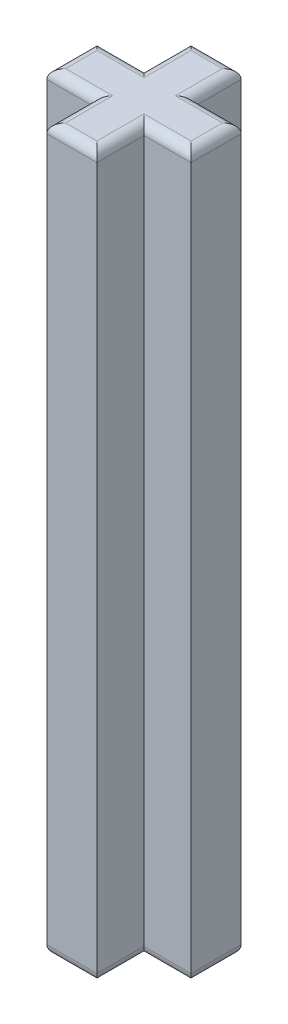
from build123d import *

# Parameters (mm, degrees)
BOSS_EXTRUDE1_DEPTH = 23
FILLET1_R           = 0.3


with BuildPart() as part:
    # Sketch1 → Boss-Extrude1 (new body)
    with BuildSketch(Plane(origin=(0, 0, 0), x_dir=(1, 0, 0), z_dir=(0, 1, 0))):
        Polygon((0.8, 0.8), (2.3, 0.8), (2.3, -0.8), (0.8, -0.8), (0.8, -2.3), (-0.8, -2.3), (-0.8, -0.8), (-2.3, -0.8), (-2.3, 0.8), (-0.8, 0.8), (-0.8, 2.3), (0.8, 2.3), align=None)
    extrude(amount=BOSS_EXTRUDE1_DEPTH)

    # Fillet1
    fillet1_edges = [part.edges().sort_by_distance(p)[0] for p in [
        (1.55, 0, 0.8),
        (0.8, 0, 1.55),
        (0.8, 23, -1.55),
        (0, 0, 2.3),
        (-0.8, 0, 1.55),
        (-1.55, 0, 0.8),
        (-2.3, 0, 0),
        (-1.55, 0, -0.8),
        (-0.8, 0, -1.55),
        (0, 0, -2.3),
        (0.8, 0, -1.55),
        (1.55, 0, -0.8),
        (2.3, 0, 0),
        (0, 23, -2.3),
        (-0.8, 23, -1.55),
        (-1.55, 23, -0.8),
        (-2.3, 23, 0),
        (-1.55, 23, 0.8),
        (-0.8, 23, 1.55),
        (0, 23, 2.3),
        (0.8, 23, 1.55),
        (1.55, 23, 0.8),
        (2.3, 23, 0),
        (1.55, 23, -0.8),
    ]]
    fillet(fillet1_edges, radius=FILLET1_R)


solid = part.part
